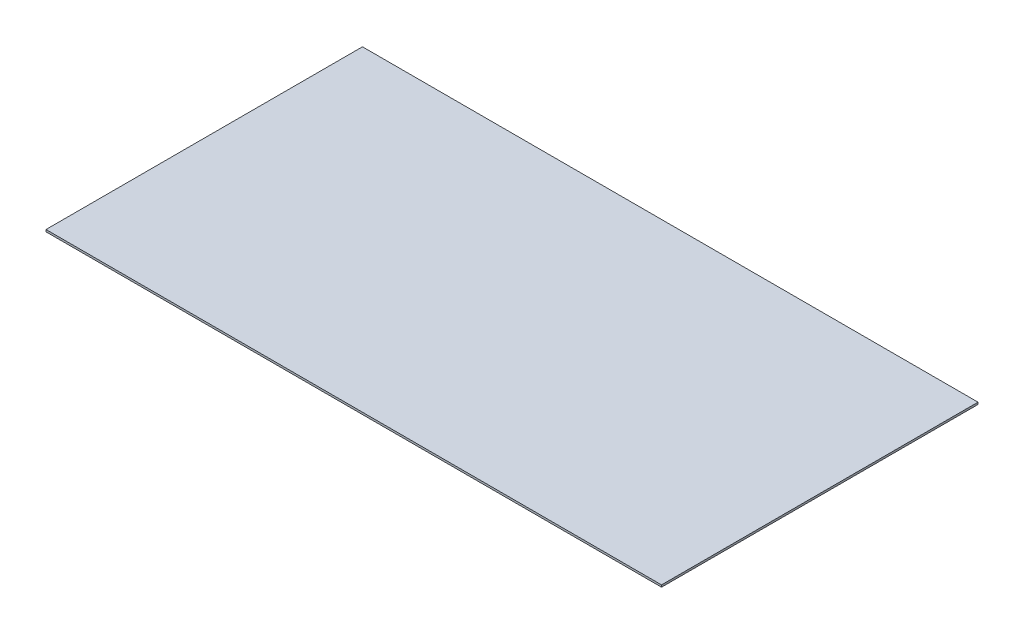
from build123d import *

# Parameters (mm, degrees)
SKETCH1_W           = 303.185960742
SKETCH1_H           = 155.872478188
BOSS_EXTRUDE1_DEPTH = 1


with BuildPart() as part:
    # Sketch1 → Boss-Extrude1 (new body)
    with BuildSketch(Plane(origin=(0, 0, 0), x_dir=(1, 0, 0), z_dir=(0, 1, 0))):
        Rectangle(SKETCH1_W, SKETCH1_H)
    extrude(amount=BOSS_EXTRUDE1_DEPTH)


solid = part.part
